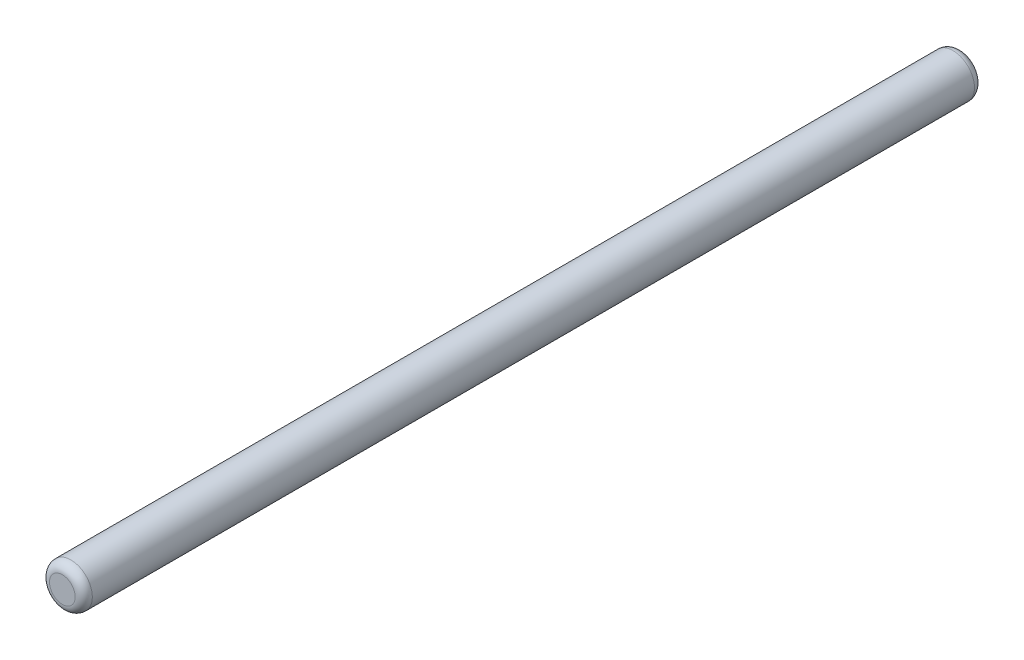
from build123d import *

# Parameters (mm, degrees)
ESQUISSE1_R        = 2.5
BOSS_EXTRU_1_DEPTH = 105
CONG_1_R           = 1


with BuildPart() as part:
    # Esquisse1 → Boss.-Extru.1 (new body)
    with BuildSketch(Plane.XY):
        Circle(ESQUISSE1_R)
    extrude(amount=BOSS_EXTRU_1_DEPTH)

    # Congé1
    cong_1_edges = [part.edges().sort_by_distance(p)[0] for p in [
        (-2.5, 0, 0),
        (-2.5, 0, 105),
    ]]
    fillet(cong_1_edges, radius=CONG_1_R)


solid = part.part
